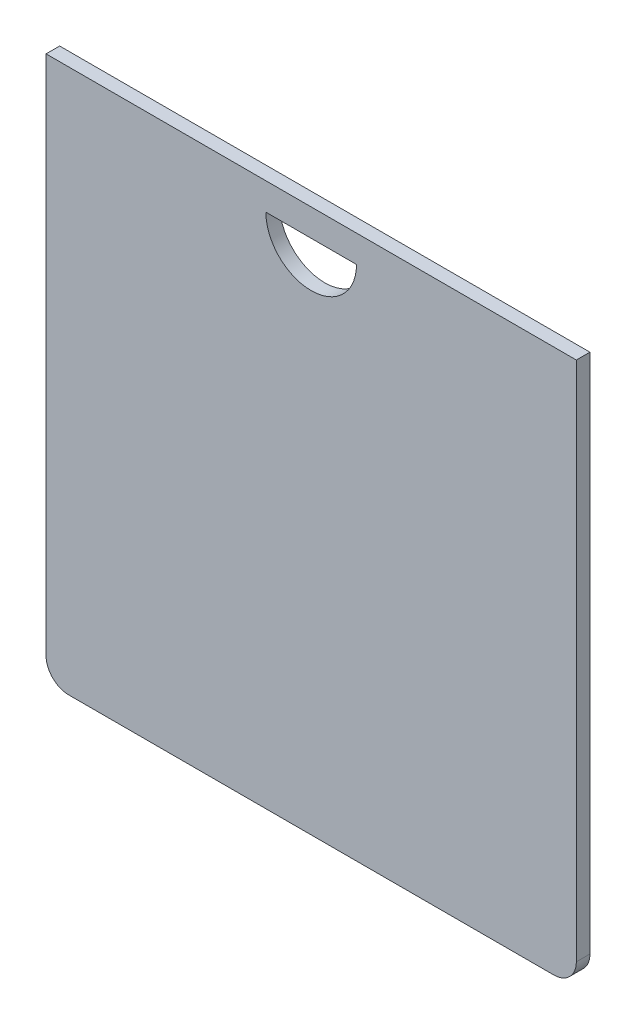
from build123d import *

# Parameters (mm, degrees)
SKETCH_1_W          = 58.5
SKETCH_1_H          = 60
EXTRUDE_1_DEPTH     = 1.5
FILLET_1_R          = 2.5
CUT_EXTRUDE_1_DEPTH = 2.5


with BuildPart() as part:
    # Эскиз1 → Бобышка-Вытянуть1 (new body)
    with BuildSketch(Plane.XY):
        with Locations((29.25, 30)):
            Rectangle(SKETCH_1_W, SKETCH_1_H)
    extrude(amount=EXTRUDE_1_DEPTH)

    # Скругление1
    fillet_1_edges = [part.edges().sort_by_distance(p)[0] for p in [
        (58.5, 0, 0.75),
        (0, 0, 0.75),
    ]]
    fillet(fillet_1_edges, radius=FILLET_1_R)

    # Эскиз2 → Вырез-Вытянуть1 (cut, through all)
    with BuildSketch(Plane.XY.offset(1.5)):
        with BuildLine():
            Line((24.25, 57), (34.25, 57))
            ThreePointArc((34.25, 57), (29.25, 52), (24.25, 57))
        make_face()
    extrude(amount=-CUT_EXTRUDE_1_DEPTH, mode=Mode.SUBTRACT)


solid = part.part
